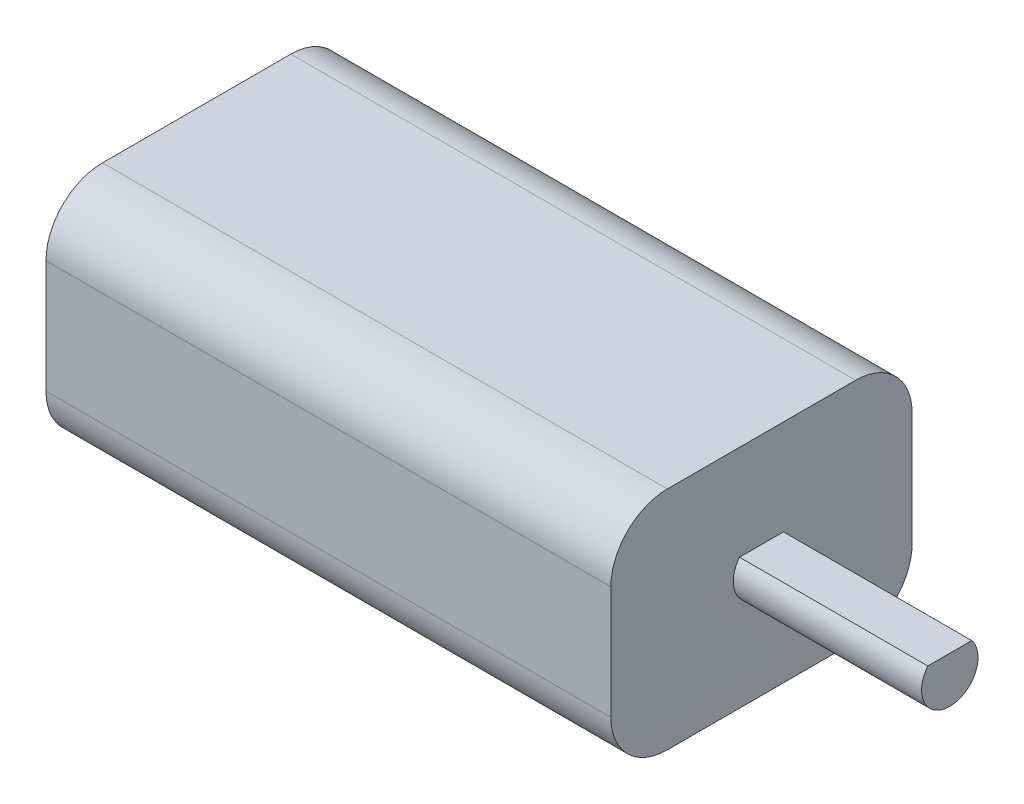
from build123d import *

# Parameters (mm, degrees)
SKETCH1_W           = 30
SKETCH1_H           = 16
BOSS_EXTRUDE1_DEPTH = 12
FILLET2_R           = 3
BOSS_EXTRUDE3_DEPTH = 10


with BuildPart() as part:
    # Sketch1 → Boss-Extrude1 (new body)
    with BuildSketch(Plane(origin=(0, 0, 0), x_dir=(1, 0, 0), z_dir=(0, 1, 0))):
        Rectangle(SKETCH1_W, SKETCH1_H)
    extrude(amount=BOSS_EXTRUDE1_DEPTH)

    # Fillet2
    fillet2_edges = [part.edges().sort_by_distance(p)[0] for p in [
        (0, 12, 8),
        (0, 0, 8),
        (0, 0, -8),
        (0, 12, -8),
    ]]
    fillet(fillet2_edges, radius=FILLET2_R)

    # Sketch3 → Boss-Extrude3 (add)
    with BuildSketch(Plane(origin=(15, 0, 0), x_dir=(0, 0, -1), z_dir=(1, 0, 0))):
        with BuildLine():
            Line((-1.166565174, 6.942934619), (1.166565174, 6.942934619))
            ThreePointArc((1.166565174, 6.942934619), (0, 4.5), (-1.166565174, 6.942934619))
        make_face()
    extrude(amount=BOSS_EXTRUDE3_DEPTH)


solid = part.part
